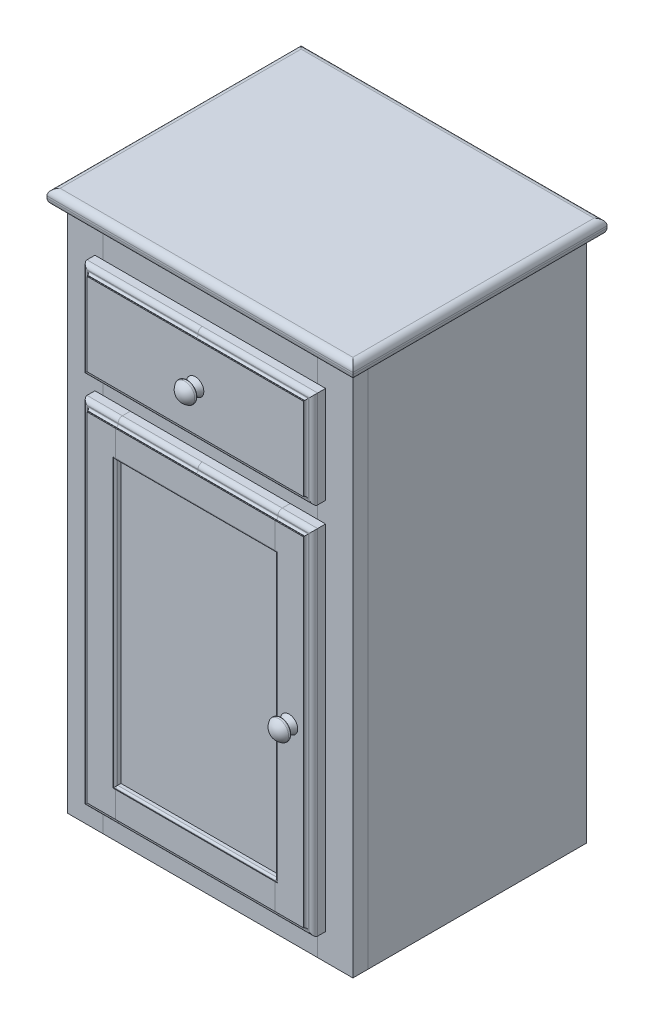
from build123d import *

# Parameters (mm, degrees)
SKETCH1_W                         = 294.64
SKETCH1_H                         = 709.93
RIGHT_SIDE_DEPTH                  = 20.32
SKETCH2_W                         = 412.75
SKETCH2_H                         = 342.9
TOP_DEPTH                         = 20.32
TOP_ROUTER_R                      = 8.89
SKETCH3_W                         = 20.32
SKETCH3_H                         = 294.64
LEFT_SIDE_DEPTH                   = 709.93
SKETCH4_W                         = 344.17
SKETCH4_H                         = 8.89
BACK_DEPTH                        = 709.93
SKETCH5_W                         = 344.17
SKETCH5_H                         = 20.32
BOTTOM_DEPTH                      = 285.75
SKETCH6_W                         = 248.666
SKETCH6_H                         = 20.32
INSIDE_FRAME_BACK_DEPTH           = 47.752
INSIDE_FRAME_BACK_2_DEPTH         = 47.752
SKETCH8_W                         = 47.752
SKETCH8_H                         = 20.32
INSIDE_FRAME_SIDES_DEPTH          = 285.75
INSIDE_FRAME_SIDES_2_DEPTH        = 285.75
INSIDE_FRAME_SIDES_3_DEPTH        = 285.75
INSIDE_FRAME_SIDES_4_DEPTH        = 285.75
SKETCH9_W                         = 47.752
SKETCH9_H                         = 20.32
INSIDE_FRAME_FRONT_DEPTH          = 248.666
INSIDE_FRAME_FRONT_2_DEPTH        = 248.666
SKETCH10_W                        = 47.752
SKETCH10_H                        = 20.32
FRONT_SIDE_STRIPS_DEPTH           = 709.93
FRONT_SIDE_STRIPS_2_DEPTH         = 709.93
SKETCH11_W                        = 20.32
SKETCH11_H                        = 47.752
FRONT_CENTER_STRIPS_DEPTH         = 289.306
FRONT_CENTER_STRIPS_2_DEPTH       = 289.306
FRONT_CENTER_STRIPS_3_DEPTH       = 289.306
SKETCH12_W                        = 311.15
SKETCH12_H                        = 130.81
TOP_DRAWER_FRONT_DEPTH            = 20.32
TOP_DRAWER_RAILS_DEPTH            = 285.75
TOP_DRAWER_RAILS_2_DEPTH          = 285.75
TOP_DRAWER_FONT_BACK_DEPTH        = 107.95
TOP_DRAWER_FONT_BACK_2_DEPTH      = 107.95
SKETCH15_W                        = 11.176
SKETCH15_H                        = 294.894
TOP_DRAWER_SIDES_DEPTH            = 107.95
TOP_DRAWER_SIDES_2_DEPTH          = 107.95
SKETCH17_W                        = 273.05
SKETCH17_H                        = 7.62
TOP_DRAWER_BOTTOM_CUTS_DEPTH      = 294.894
SKETCH18_W                        = 273.05
SKETCH18_H                        = 7.62
TOP_DRAWER_BOTTOM_DEPTH           = 294.894
SKETCH24_W                        = 47.752
SKETCH24_H                        = 476.25
BOTTOM_DOOR_SIDES_DEPTH           = 20.32
BOTTOM_DOOR_SIDES_2_DEPTH         = 20.32
SKETCH25_W                        = 215.646
SKETCH25_H                        = 47.752
BOTTOM_DOOR_CENTERS_DEPTH         = 20.32
BOTTOM_DOOR_CENTERS_2_DEPTH       = 20.32
SKETCH26_W                        = 241.046
SKETCH26_H                        = 406.146
BOTTOM_DOOR_PANEL_CUTS_DEPTH      = 2.54
BOTTOM_DOOR_PANEL_CUTS_DEPTH_BACK = 2.54
SKETCH27_W                        = 241.046
SKETCH27_H                        = 406.146
BOTTOM_DOOR_PANEL_DEPTH           = 2.54
BOTTOM_DOOR_PANEL_DEPTH_BACK      = 2.54


with BuildPart() as part:
    # Sketch1 → Right Side (new body)
    with BuildSketch(Plane(origin=(0, 0, 0), x_dir=(0, 0, -1), z_dir=(1, 0, 0))):
        with Locations((-147.32, 354.965)):
            Rectangle(SKETCH1_W, SKETCH1_H)
    extrude(amount=-RIGHT_SIDE_DEPTH)


with BuildPart() as body_2:
    # Sketch2 → Top (new body)
    with BuildSketch(Plane(origin=(0, 709.93, 0), x_dir=(1, 0, 0), z_dir=(0, 1, 0))):
        with Locations((-192.405, -157.48)):
            Rectangle(SKETCH2_W, SKETCH2_H)
    extrude(amount=TOP_DEPTH)

    # Top Router
    top_router_edges = [body_2.edges().sort_by_distance(p)[0] for p in [
        (-398.78, 730.25, 157.48),
        (-192.405, 730.25, 328.93),
        (13.97, 730.25, 157.48),
        (-192.405, 709.93, 328.93),
        (-398.78, 709.93, 157.48),
        (-192.405, 709.93, -13.97),
        (13.97, 709.93, 157.48),
        (-192.405, 730.25, -13.97),
    ]]
    fillet(top_router_edges, radius=TOP_ROUTER_R)


with BuildPart() as body_3:
    # Sketch3 → Left Side (new body)
    with BuildSketch(Plane.XZ.offset(-709.93)):
        with Locations((-374.65, 147.32)):
            Rectangle(SKETCH3_W, SKETCH3_H)
    extrude(amount=LEFT_SIDE_DEPTH)


with BuildPart() as body_4:
    # Sketch4 → Back (new body)
    with BuildSketch(Plane.XZ.offset(-709.93)):
        with Locations((-192.405, 4.445)):
            Rectangle(SKETCH4_W, SKETCH4_H)
    extrude(amount=BACK_DEPTH)


with BuildPart() as body_5:
    # Sketch5 → Bottom (new body)
    with BuildSketch(Plane.XY.offset(8.89)):
        with Locations((-192.405, 22.86)):
            Rectangle(SKETCH5_W, SKETCH5_H)
    extrude(amount=BOTTOM_DEPTH)


with BuildPart() as body_6:
    # Sketch6 → Inside Frame - Back (new body)
    with BuildSketch(Plane.XY.offset(8.89)):
        with Locations((-192.405, 699.77)):
            Rectangle(SKETCH6_W, SKETCH6_H)
    extrude(amount=INSIDE_FRAME_BACK_DEPTH)


with BuildPart() as body_7:
    # Sketch6 → Inside Frame - Back 2 (new body)
    with BuildSketch(Plane.XY.offset(8.89)):
        with Locations((-192.405, 537.718)):
            Rectangle(SKETCH6_W, SKETCH6_H)
    extrude(amount=INSIDE_FRAME_BACK_2_DEPTH)


with BuildPart() as body_8:
    # Sketch8 → Inside Frame - Sides (new body)
    with BuildSketch(Plane.XY.offset(8.89)):
        with Locations((-340.614, 699.77)):
            Rectangle(SKETCH8_W, SKETCH8_H)
    extrude(amount=INSIDE_FRAME_SIDES_DEPTH)


with BuildPart() as body_9:
    # Sketch8 → Inside Frame - Sides 2 (new body)
    with BuildSketch(Plane.XY.offset(8.89)):
        with Locations((-44.196, 699.77)):
            Rectangle(SKETCH8_W, SKETCH8_H)
    extrude(amount=INSIDE_FRAME_SIDES_2_DEPTH)


with BuildPart() as body_10:
    # Sketch8 → Inside Frame - Sides 3 (new body)
    with BuildSketch(Plane.XY.offset(8.89)):
        with Locations((-340.614, 537.718)):
            Rectangle(SKETCH8_W, SKETCH8_H)
    extrude(amount=INSIDE_FRAME_SIDES_3_DEPTH)


with BuildPart() as body_11:
    # Sketch8 → Inside Frame - Sides 4 (new body)
    with BuildSketch(Plane.XY.offset(8.89)):
        with Locations((-44.196, 537.718)):
            Rectangle(SKETCH8_W, SKETCH8_H)
    extrude(amount=INSIDE_FRAME_SIDES_4_DEPTH)


with BuildPart() as body_12:
    # Sketch9 → Inside Frame - Front (new body)
    with BuildSketch(Plane.ZY.offset(68.072)):
        with Locations((270.764, 699.77)):
            Rectangle(SKETCH9_W, SKETCH9_H)
    extrude(amount=INSIDE_FRAME_FRONT_DEPTH)


with BuildPart() as body_13:
    # Sketch9 → Inside Frame - Front 2 (new body)
    with BuildSketch(Plane.ZY.offset(68.072)):
        with Locations((270.764, 537.718)):
            Rectangle(SKETCH9_W, SKETCH9_H)
    extrude(amount=INSIDE_FRAME_FRONT_2_DEPTH)


with BuildPart() as body_14:
    # Sketch10 → Front - Side Strips (new body)
    with BuildSketch(Plane.XZ.offset(-709.93)):
        with Locations((-23.876, 304.8)):
            Rectangle(SKETCH10_W, SKETCH10_H)
    extrude(amount=FRONT_SIDE_STRIPS_DEPTH)


with BuildPart() as body_15:
    # Sketch10 → Front - Side Strips 2 (new body)
    with BuildSketch(Plane.XZ.offset(-709.93)):
        with Locations((-360.934, 304.8)):
            Rectangle(SKETCH10_W, SKETCH10_H)
    extrude(amount=FRONT_SIDE_STRIPS_2_DEPTH)


with BuildPart() as body_16:
    # Sketch11 → Front - Center Strips (new body)
    with BuildSketch(Plane.ZY.offset(47.752)):
        with Locations((304.8, 686.054)):
            Rectangle(SKETCH11_W, SKETCH11_H)
    extrude(amount=FRONT_CENTER_STRIPS_DEPTH)


with BuildPart() as body_17:
    # Sketch11 → Front - Center Strips 2 (new body)
    with BuildSketch(Plane.ZY.offset(47.752)):
        with Locations((304.8, 524.002)):
            Rectangle(SKETCH11_W, SKETCH11_H)
    extrude(amount=FRONT_CENTER_STRIPS_2_DEPTH)


with BuildPart() as body_18:
    # Sketch11 → Front - Center Strips 3 (new body)
    with BuildSketch(Plane.ZY.offset(47.752)):
        with Locations((304.8, 23.876)):
            Rectangle(SKETCH11_W, SKETCH11_H)
    extrude(amount=FRONT_CENTER_STRIPS_3_DEPTH)


with BuildPart() as body_19:
    # Sketch12 → Top Drawer - Front (new body)
    with BuildSketch(Plane.XY.offset(314.96)):
        with Locations((-192.405, 605.028)):
            Rectangle(SKETCH12_W, SKETCH12_H)
    extrude(amount=TOP_DRAWER_FRONT_DEPTH)

    # Top Drawer - Router: sweep along a path in Sketch20
    with BuildLine(Plane.XY.offset(335.28)) as top_drawer_router_path:
        Line((-36.83, 670.433), (-347.98, 670.433))
        Line((-347.98, 670.433), (-347.98, 539.623))
        Line((-347.98, 539.623), (-36.83, 539.623))
        Line((-36.83, 539.623), (-36.83, 670.433))
    # Sketch19 → Top Drawer - Router (sweep, cut)
    with BuildSketch(Plane(origin=(-192.405, 0, 0), x_dir=(0, 0, -1), z_dir=(1, 0, 0))):
        with BuildLine():
            Line((-314.96, 670.433), (-325.665472249, 670.433))
            ThreePointArc((-325.665472249, 670.433), (-329.769893183, 668.732893183), (-331.47, 664.628472249))
            Line((-331.47, 664.628472249), (-331.47, 663.790621279))
            ThreePointArc((-331.47, 663.790621279), (-332.213948776, 661.994570054), (-334.01, 661.250621279))
            Line((-334.01, 661.250621279), (-334.01, 660.742621279))
            Line((-334.01, 660.742621279), (-340.36, 660.742621279))
            Line((-340.36, 660.742621279), (-340.36, 686.142621279))
            Line((-340.36, 686.142621279), (-314.96, 686.142621279))
            Line((-314.96, 686.142621279), (-314.96, 670.433))
        make_face()
    sweep(path=top_drawer_router_path.line, transition=Transition.RIGHT, mode=Mode.SUBTRACT)

    # Sketch23 → Top Drawer - Knob (revolve)
    with BuildSketch(Plane(origin=(-192.405, 0, 0), x_dir=(0, 0, -1), z_dir=(1, 0, 0)), mode=Mode.PRIVATE) as top_drawer_knob_sk:
        with BuildLine():
            Line((-335.28, 604.901), (-357.298956817, 604.901))
            ThreePointArc((-357.298956817, 604.901), (-355.176465036, 612.698331531), (-349.394672639, 618.344057973))
            ThreePointArc((-349.394672639, 618.344057973), (-346.958470751, 618.482120968), (-345.340015299, 616.655993103))
            ThreePointArc((-345.340015299, 616.655993103), (-345.047721802, 615.254080337), (-344.949677893, 613.825380828))
            ThreePointArc((-344.949677893, 613.825380828), (-344.465983548, 612.868802323), (-343.408860385, 612.691338875))
            ThreePointArc((-343.408860385, 612.691338875), (-339.20996547, 614.32818656), (-335.28, 616.533942725))
            Line((-335.28, 616.533942725), (-335.28, 604.901))
        make_face()
    revolve(top_drawer_knob_sk.sketch.rotate(Axis((-192.405, 604.901, 335.28), (0, 0, 1)), 90), axis=Axis((-192.405, 604.901, 335.28), (0, 0, 1)))  # turned: the seam where the file's is


with BuildPart() as body_20:
    # Sketch13 → Top Drawer - Rails (new body)
    with BuildSketch(Plane(origin=(0, 0, 294.64), x_dir=(-1, 0, 0), z_dir=(0, 0, -1))):
        Polygon((20.32, 568.198), (47.752, 568.198), (47.752, 555.498), (68.072, 555.498), (68.072, 547.878), (20.32, 547.878), align=None)
    extrude(amount=TOP_DRAWER_RAILS_DEPTH)


with BuildPart() as body_21:
    # Sketch13 → Top Drawer - Rails 2 (new body)
    with BuildSketch(Plane(origin=(0, 0, 294.64), x_dir=(-1, 0, 0), z_dir=(0, 0, -1))):
        Polygon((364.49, 547.878), (316.738, 547.878), (316.738, 555.498), (337.058, 555.498), (337.058, 568.198), (364.49, 568.198), align=None)
    extrude(amount=TOP_DRAWER_RAILS_2_DEPTH)


with BuildPart() as body_22:
    # Sketch14 → Top Drawer - Font / Back (new body)
    with BuildSketch(Plane(origin=(0, 555.498, 0), x_dir=(1, 0, 0), z_dir=(0, 1, 0))):
        Polygon((-334.518, -14.478), (-334.518, -8.89), (-50.292, -8.89), (-50.292, -14.478), (-61.468, -14.478), (-61.468, -20.066), (-323.342, -20.066), (-323.342, -14.478), align=None)
    extrude(amount=TOP_DRAWER_FONT_BACK_DEPTH)


with BuildPart() as body_23:
    # Sketch14 → Top Drawer - Font _ Back 2 (new body)
    with BuildSketch(Plane(origin=(0, 555.498, 0), x_dir=(1, 0, 0), z_dir=(0, 1, 0))):
        Polygon((-334.518, -314.96), (-50.292, -314.96), (-50.292, -309.372), (-61.468, -309.372), (-61.468, -303.784), (-323.342, -303.784), (-323.342, -309.372), (-334.518, -309.372), align=None)
    extrude(amount=TOP_DRAWER_FONT_BACK_2_DEPTH)


with BuildPart() as body_24:
    # Sketch15 → Top Drawer - Sides (new body)
    with BuildSketch(Plane(origin=(0, 555.498, 0), x_dir=(1, 0, 0), z_dir=(0, 1, 0))):
        with Locations((-328.93, -161.925)):
            Rectangle(SKETCH15_W, SKETCH15_H)
    extrude(amount=TOP_DRAWER_SIDES_DEPTH)


with BuildPart() as body_25:
    # Sketch15 → Top Drawer - Sides 2 (new body)
    with BuildSketch(Plane(origin=(0, 555.498, 0), x_dir=(1, 0, 0), z_dir=(0, 1, 0))):
        with Locations((-55.88, -161.925)):
            Rectangle(SKETCH15_W, SKETCH15_H)
    extrude(amount=TOP_DRAWER_SIDES_2_DEPTH)


with BuildPart() as top_drawer_bottom_cuts_tool:
    # Sketch17 → Top Drawer - Bottom Cuts (new body)
    with BuildSketch(Plane.XY.offset(309.372)):
        with Locations((-192.405, 565.785)):
            Rectangle(SKETCH17_W, SKETCH17_H)
    extrude(amount=-TOP_DRAWER_BOTTOM_CUTS_DEPTH)


with BuildPart() as body_22_1:
    add(body_22.part)

    # Top Drawer - Bottom Cuts: cut by top_drawer_bottom_cuts_tool
    add(top_drawer_bottom_cuts_tool.part, mode=Mode.SUBTRACT)


with BuildPart() as body_23_1:
    add(body_23.part)

    # Top Drawer - Bottom Cuts: cut by top_drawer_bottom_cuts_tool
    add(top_drawer_bottom_cuts_tool.part, mode=Mode.SUBTRACT)


with BuildPart() as body_24_1:
    add(body_24.part)

    # Top Drawer - Bottom Cuts: cut by top_drawer_bottom_cuts_tool
    add(top_drawer_bottom_cuts_tool.part, mode=Mode.SUBTRACT)


with BuildPart() as body_25_1:
    add(body_25.part)

    # Top Drawer - Bottom Cuts: cut by top_drawer_bottom_cuts_tool
    add(top_drawer_bottom_cuts_tool.part, mode=Mode.SUBTRACT)


with BuildPart() as body_26:
    # Sketch18 → Top Drawer - Bottom (new body)
    with BuildSketch(Plane.XY.offset(309.372)):
        with Locations((-192.405, 565.785)):
            Rectangle(SKETCH18_W, SKETCH18_H)
    extrude(amount=-TOP_DRAWER_BOTTOM_DEPTH)


with BuildPart() as body_27:
    # Sketch24 → Bottom Door - Sides (new body)
    with BuildSketch(Plane.XY.offset(314.96)):
        with Locations((-60.706, 273.939)):
            Rectangle(SKETCH24_W, SKETCH24_H)
    extrude(amount=BOTTOM_DOOR_SIDES_DEPTH)


with BuildPart() as body_28:
    # Sketch24 → Bottom Door - Sides 2 (new body)
    with BuildSketch(Plane.XY.offset(314.96)):
        with Locations((-324.104, 273.939)):
            Rectangle(SKETCH24_W, SKETCH24_H)
    extrude(amount=BOTTOM_DOOR_SIDES_2_DEPTH)


with BuildPart() as body_29:
    # Sketch25 → Bottom Door - Centers (new body)
    with BuildSketch(Plane.XY.offset(314.96)):
        with Locations((-192.405, 488.188)):
            Rectangle(SKETCH25_W, SKETCH25_H)
    extrude(amount=BOTTOM_DOOR_CENTERS_DEPTH)


with BuildPart() as body_30:
    # Sketch25 → Bottom Door - Centers 2 (new body)
    with BuildSketch(Plane.XY.offset(314.96)):
        with Locations((-192.405, 59.69)):
            Rectangle(SKETCH25_W, SKETCH25_H)
    extrude(amount=BOTTOM_DOOR_CENTERS_2_DEPTH)


with BuildPart() as bottom_door_panel_cuts_tool:
    # Sketch26 → Bottom Door - Panel Cuts (new body, two sides)
    with BuildSketch(Plane.XY.offset(325.12)) as bottom_door_panel_cuts_sk:
        with Locations((-192.405, 273.939)):
            Rectangle(SKETCH26_W, SKETCH26_H)
    extrude(amount=BOTTOM_DOOR_PANEL_CUTS_DEPTH)
    extrude(bottom_door_panel_cuts_sk.sketch, amount=-BOTTOM_DOOR_PANEL_CUTS_DEPTH_BACK)


with BuildPart() as body_27_1:
    add(body_27.part)

    # Bottom Door - Panel Cuts: cut by bottom_door_panel_cuts_tool
    add(bottom_door_panel_cuts_tool.part, mode=Mode.SUBTRACT)


with BuildPart() as body_28_1:
    add(body_28.part)

    # Bottom Door - Panel Cuts: cut by bottom_door_panel_cuts_tool
    add(bottom_door_panel_cuts_tool.part, mode=Mode.SUBTRACT)


with BuildPart() as body_29_1:
    add(body_29.part)

    # Bottom Door - Panel Cuts: cut by bottom_door_panel_cuts_tool
    add(bottom_door_panel_cuts_tool.part, mode=Mode.SUBTRACT)


with BuildPart() as body_30_1:
    add(body_30.part)

    # Bottom Door - Panel Cuts: cut by bottom_door_panel_cuts_tool
    add(bottom_door_panel_cuts_tool.part, mode=Mode.SUBTRACT)


with BuildPart() as body_31:
    # Sketch27 → Bottom Door - Panel (new body, two sides)
    with BuildSketch(Plane.XY.offset(325.12)) as bottom_door_panel_sk:
        with Locations((-192.405, 273.939)):
            Rectangle(SKETCH27_W, SKETCH27_H)
    extrude(amount=BOTTOM_DOOR_PANEL_DEPTH)
    extrude(bottom_door_panel_sk.sketch, amount=-BOTTOM_DOOR_PANEL_DEPTH_BACK)


with BuildPart() as bottom_door_router_outside_tool:
    # Bottom Door - Router Outside: sweep along a path in Sketch21
    with BuildLine(Plane.XY.offset(335.28)) as bottom_door_router_outside_path:
        Line((-36.83, 512.064), (-347.98, 512.064))
        Line((-347.98, 512.064), (-347.98, 35.814))
        Line((-347.98, 35.814), (-36.83, 35.814))
        Line((-36.83, 35.814), (-36.83, 512.064))
    # Sketch22 → Bottom Door - Router Outside (sweep)
    with BuildSketch(Plane(origin=(-192.405, 0, 0), x_dir=(0, 0, -1), z_dir=(1, 0, 0))):
        with BuildLine():
            Line((-314.96, 512.064), (-325.665472249, 512.064))
            ThreePointArc((-325.665472249, 512.064), (-329.769893183, 510.363893183), (-331.47, 506.259472249))
            Line((-331.47, 506.259472249), (-331.47, 505.421621279))
            ThreePointArc((-331.47, 505.421621279), (-332.213948776, 503.625570054), (-334.01, 502.881621279))
            Line((-334.01, 502.881621279), (-334.01, 502.373621279))
            Line((-334.01, 502.373621279), (-340.36, 502.373621279))
            Line((-340.36, 502.373621279), (-340.36, 527.773621279))
            Line((-340.36, 527.773621279), (-314.96, 527.773621279))
            Line((-314.96, 527.773621279), (-314.96, 512.064))
        make_face()
    sweep(path=bottom_door_router_outside_path.line, transition=Transition.RIGHT)


with BuildPart() as body_27_2:
    add(body_27_1.part)

    # Bottom Door - Router Outside: cut by bottom_door_router_outside_tool
    add(bottom_door_router_outside_tool.part, mode=Mode.SUBTRACT)


with BuildPart() as body_28_2:
    add(body_28_1.part)

    # Bottom Door - Router Outside: cut by bottom_door_router_outside_tool
    add(bottom_door_router_outside_tool.part, mode=Mode.SUBTRACT)


with BuildPart() as body_29_2:
    add(body_29_1.part)

    # Bottom Door - Router Outside: cut by bottom_door_router_outside_tool
    add(bottom_door_router_outside_tool.part, mode=Mode.SUBTRACT)


with BuildPart() as body_30_2:
    add(body_30_1.part)

    # Bottom Door - Router Outside: cut by bottom_door_router_outside_tool
    add(bottom_door_router_outside_tool.part, mode=Mode.SUBTRACT)


with BuildPart() as body_32:
    # Sketch28 → Bottom Door - Knob (revolve)
    with BuildSketch(Plane(origin=(-65.786, 0, 0), x_dir=(0, 0, -1), z_dir=(1, 0, 0)), mode=Mode.PRIVATE) as bottom_door_knob_sk:
        with BuildLine():
            Line((-335.28, 273.939), (-357.298956817, 273.939))
            ThreePointArc((-357.298956817, 273.939), (-355.176465036, 281.736331531), (-349.394672639, 287.382057973))
            ThreePointArc((-349.394672639, 287.382057973), (-346.958470751, 287.520120968), (-345.340015299, 285.693993103))
            ThreePointArc((-345.340015299, 285.693993103), (-345.047721802, 284.292080337), (-344.949677893, 282.863380828))
            ThreePointArc((-344.949677893, 282.863380828), (-344.465983548, 281.906802323), (-343.408860385, 281.729338875))
            ThreePointArc((-343.408860385, 281.729338875), (-339.20996547, 283.36618656), (-335.28, 285.571942725))
            Line((-335.28, 285.571942725), (-335.28, 273.939))
        make_face()
    revolve(bottom_door_knob_sk.sketch.rotate(Axis((-65.786, 273.939, 335.28), (0, 0, 1)), 90), axis=Axis((-65.786, 273.939, 335.28), (0, 0, 1)))  # turned: the seam where the file's is


with BuildPart() as bottom_door_router_inside_tool:
    # Bottom Door - Router Inside: sweep along a path in Sketch31
    with BuildLine(Plane.XY.offset(335.28)) as bottom_door_router_inside_path:
        Line((-300.228, 464.312), (-84.582, 464.312))
        Line((-84.582, 464.312), (-84.582, 83.566))
        Line((-84.582, 83.566), (-300.228, 83.566))
        Line((-300.228, 83.566), (-300.228, 464.312))
    # Sketch29 → Bottom Door - Router Inside (sweep)
    with BuildSketch(Plane(origin=(-192.405, 0, 0), x_dir=(0, 0, -1), z_dir=(1, 0, 0))):
        with BuildLine():
            Line((-334.645, 467.487), (-335.28, 467.487))
            Line((-335.28, 467.487), (-342.985769957, 467.487))
            Line((-342.985769957, 467.487), (-342.985769957, 454.787))
            Line((-342.985769957, 454.787), (-327.66, 454.787))
            Line((-327.66, 454.787), (-327.66, 464.312))
            Line((-327.66, 464.312), (-332.105, 464.312))
            ThreePointArc((-332.105, 464.312), (-333.901051224, 465.055948776), (-334.645, 466.852))
            Line((-334.645, 466.852), (-334.645, 467.487))
        make_face()
    sweep(path=bottom_door_router_inside_path.line, transition=Transition.RIGHT)


with BuildPart() as body_27_3:
    add(body_27_2.part)

    # Bottom Door - Router Inside: cut by bottom_door_router_inside_tool
    add(bottom_door_router_inside_tool.part, mode=Mode.SUBTRACT)


with BuildPart() as body_28_3:
    add(body_28_2.part)

    # Bottom Door - Router Inside: cut by bottom_door_router_inside_tool
    add(bottom_door_router_inside_tool.part, mode=Mode.SUBTRACT)


with BuildPart() as body_29_3:
    add(body_29_2.part)

    # Bottom Door - Router Inside: cut by bottom_door_router_inside_tool
    add(bottom_door_router_inside_tool.part, mode=Mode.SUBTRACT)


with BuildPart() as body_30_3:
    add(body_30_2.part)

    # Bottom Door - Router Inside: cut by bottom_door_router_inside_tool
    add(bottom_door_router_inside_tool.part, mode=Mode.SUBTRACT)


solid = Compound([part.part, body_2.part, body_3.part, body_4.part, body_5.part, body_6.part, body_7.part, body_8.part, body_9.part, body_10.part, body_11.part, body_12.part, body_13.part, body_14.part, body_15.part, body_16.part, body_17.part, body_18.part, body_19.part, body_20.part, body_21.part, body_22_1.part, body_23_1.part, body_24_1.part, body_25_1.part, body_26.part, body_31.part, body_32.part, body_27_3.part, body_28_3.part, body_29_3.part, body_30_3.part])
